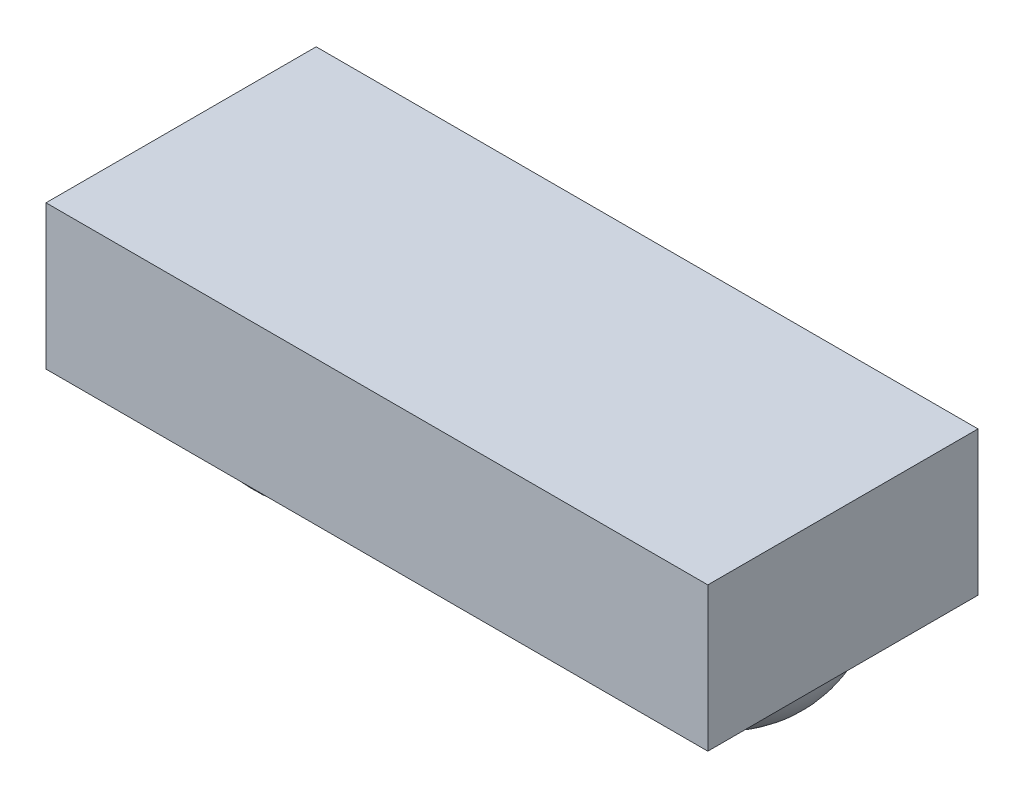
from build123d import *

# Parameters (mm, degrees)
BOSS_EXTRUDE1_DEPTH = 4.07
SKETCH1_3_W         = 1.75
SKETCH1_3_H         = 0.63
BOSS_EXTRUDE2_DEPTH = 0.2


with BuildPart() as part:
    # Sketch1 → Boss-Extrude1 (new body)
    with BuildSketch(Plane.XY):
        Polygon((4.985, 1.420440613), (4.985, 3.590440613), (-4.985, 3.590440613), (-4.985, 1.420440613), (-0.875, 1.420440613), (0.875, 1.420440613), align=None)
    extrude(amount=BOSS_EXTRUDE1_DEPTH)

    # Sketch1_3 → Boss-Extrude2 (add)
    with BuildSketch(Plane.XY):
        with Locations((0, 1.105440613)):
            Rectangle(SKETCH1_3_W, SKETCH1_3_H)
    extrude(amount=BOSS_EXTRUDE2_DEPTH)

    # Sketch2 → Revolve1 (revolve)
    with BuildSketch(Plane.XY.offset(1.78)):
        with BuildLine():
            Line((-3.005, 1.420440613), (-4.605, 1.420440613))
            Line((-4.605, 1.420440613), (-4.605, 1.380440613))
            ThreePointArc((-4.605, 1.380440613), (-4.13637085, 0.249069763), (-3.005, -0.219559387))
            Line((-3.005, -0.219559387), (-3.005, 1.420440613))
        make_face()
    revolve(axis=Axis((-3.005, 1.420440613, 1.78), (0, -1, 0)))

    # Sketch3 → Revolve2 (revolve)
    with BuildSketch(Plane.XY.offset(1.9)):
        with BuildLine():
            Line((3.105, 1.620440613), (1.505, 1.620440613))
            ThreePointArc((1.505, 1.620440613), (1.97362915, 0.489069763), (3.105, 0.020440613))
            Line((3.105, 0.020440613), (3.105, 1.620440613))
        make_face()
    revolve(axis=Axis((3.105, 1.620440613, 1.9), (0, -1, 0)))


solid = part.part
